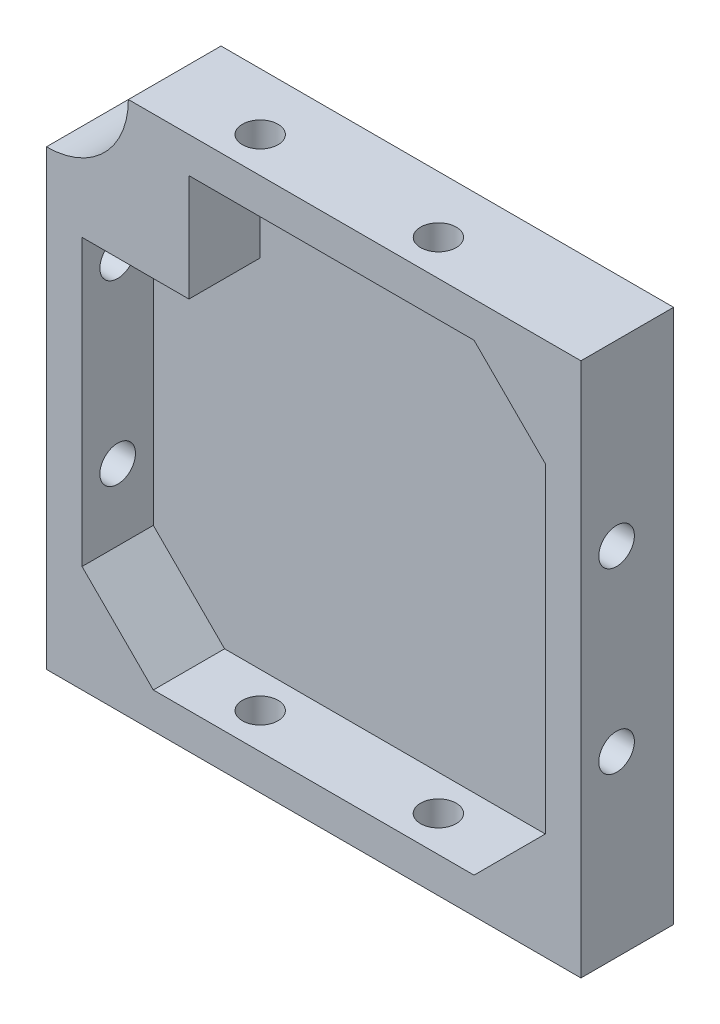
from build123d import *

# Parameters (mm, degrees)
BOSS_EXTRU_1_DEPTH        = 13
COQUE1_T                  = -5
COQUE1_THICKNESS_2_FACE_W = 65
COQUE1_THICKNESS_2_FACE_H = 65
COQUE1_THICKNESS_2_DEPTH  = 2
ENL_V_MAT_EXTRU_1_REACH   = 88.587
ESQUISSE2_R               = 2.5
ENL_V_MAT_EXTRU_2_REACH   = 95.396
ESQUISSE3_R               = 2.5
ESQUISSE4_W               = 15
ESQUISSE4_H               = 15
BOSS_EXTRU_2_DEPTH        = 10
ESQUISSE5_R               = 11.5
ENL_V_MAT_EXTRU_3_DEPTH   = 13


with BuildPart() as part:
    # Esquisse1 → Boss.-Extru.1 (new body)
    with BuildSketch(Plane.XY):
        Polygon((44.118436308, 33.728448276), (54.118436308, 33.728448276), (54.118436308, 23.728448276), (54.118436308, -41.271551724), (-20.881563692, -41.271551724), (-20.881563692, 33.728448276), align=None)
    extrude(amount=BOSS_EXTRU_1_DEPTH)

    # Coque1
    coque1_openings = [part.faces().sort_by_distance(p)[0] for p in [
        (16.618436308, -3.771551724, 13),
    ]]
    offset(amount=COQUE1_T, openings=coque1_openings, kind=Kind.INTERSECTION)

    # Coque1 thickness 2 face (on inner face of the shell) → Coque1 thickness 2 (cut)
    with BuildSketch(Plane(origin=(16.618436308, -3.771551724, 5), x_dir=(-1, 0, 0), z_dir=(0, 0, -1))):
        Rectangle(COQUE1_THICKNESS_2_FACE_W, COQUE1_THICKNESS_2_FACE_H)
    extrude(amount=COQUE1_THICKNESS_2_DEPTH, mode=Mode.SUBTRACT)

    # Enlèv. mat.-Extru.1: up to this face of the body (flat: up to its plane)
    enl_v_mat_extru_1_end = Plane(part.part.faces().sort_by_distance((54.118436308, -3.771551724, 6.5))[0])
    # Esquisse2 → Enlèv. mat.-Extru.1 (cut, up to the picked face)
    with BuildSketch(Plane.ZY.offset(20.881563692), mode=Mode.PRIVATE) as enl_v_mat_extru_1_sk1:
        with Locations(Location((8, -16.271551724, 0), (0, 0, 270))):
            Circle(ESQUISSE2_R)
    enl_v_mat_extru_1_tool1 = split(extrude(enl_v_mat_extru_1_sk1.sketch, amount=-ENL_V_MAT_EXTRU_1_REACH, mode=Mode.PRIVATE), bisect_by=enl_v_mat_extru_1_end, keep=Keep.BOTH, mode=Mode.PRIVATE)
    # Esquisse2 → Enlèv. mat.-Extru.1 (cut, up to the picked face)
    with BuildSketch(Plane.ZY.offset(20.881563692), mode=Mode.PRIVATE) as enl_v_mat_extru_1_sk2:
        with Locations(Location((8, 8.728448276, 0), (0, 0, 270))):
            Circle(ESQUISSE2_R)
    enl_v_mat_extru_1_tool2 = split(extrude(enl_v_mat_extru_1_sk2.sketch, amount=-ENL_V_MAT_EXTRU_1_REACH, mode=Mode.PRIVATE), bisect_by=enl_v_mat_extru_1_end, keep=Keep.BOTH, mode=Mode.PRIVATE)
    add(enl_v_mat_extru_1_tool1.solids().sort_by(Axis((-20.881564, -16.271552, 8), (1, 0, 0)))[0], mode=Mode.SUBTRACT)
    add(enl_v_mat_extru_1_tool2.solids().sort_by(Axis((-20.881564, 8.728448, 8), (1, 0, 0)))[0], mode=Mode.SUBTRACT)

    # Enlèv. mat.-Extru.2: up to this face of the body (flat: up to its plane)
    enl_v_mat_extru_2_end = Plane(part.part.faces().sort_by_distance((16.618436308, 33.728448276, 6.5))[0])
    # Esquisse3 → Enlèv. mat.-Extru.2 (cut, up to the picked face)
    with BuildSketch(Plane.XZ.offset(41.271551724), mode=Mode.PRIVATE) as enl_v_mat_extru_2_sk1:
        with Locations(Location((4.118436308, 8, 0), (0, 0, 270))):
            Circle(ESQUISSE3_R)
    enl_v_mat_extru_2_tool1 = split(extrude(enl_v_mat_extru_2_sk1.sketch, amount=-ENL_V_MAT_EXTRU_2_REACH, mode=Mode.PRIVATE), bisect_by=enl_v_mat_extru_2_end, keep=Keep.BOTH, mode=Mode.PRIVATE)
    # Esquisse3 → Enlèv. mat.-Extru.2 (cut, up to the picked face)
    with BuildSketch(Plane.XZ.offset(41.271551724), mode=Mode.PRIVATE) as enl_v_mat_extru_2_sk2:
        with Locations(Location((29.118436308, 8, 0), (0, 0, 270))):
            Circle(ESQUISSE3_R)
    enl_v_mat_extru_2_tool2 = split(extrude(enl_v_mat_extru_2_sk2.sketch, amount=-ENL_V_MAT_EXTRU_2_REACH, mode=Mode.PRIVATE), bisect_by=enl_v_mat_extru_2_end, keep=Keep.BOTH, mode=Mode.PRIVATE)
    add(enl_v_mat_extru_2_tool1.solids().sort_by(Axis((4.118436, -41.271552, 8), (0, 1, 0)))[0], mode=Mode.SUBTRACT)
    add(enl_v_mat_extru_2_tool2.solids().sort_by(Axis((29.118436, -41.271552, 8), (0, 1, 0)))[0], mode=Mode.SUBTRACT)

    # Esquisse4 → Boss.-Extru.2 (add)
    with BuildSketch(Plane.XY.offset(3)):
        Polygon((-15.881563692, -26.271551724), (-5.881563692, -36.271551724), (-15.881563692, -36.271551724), align=None)
        Polygon((49.118436308, 28.728448276), (49.118436308, 18.728448276), (39.118436308, 28.728448276), align=None)
        Polygon((49.118436308, -36.271551724), (49.118436308, -26.271551724), (39.118436308, -36.271551724), align=None)
        with Locations((-8.381563692, 21.228448276)):
            Rectangle(ESQUISSE4_W, ESQUISSE4_H)
    extrude(amount=BOSS_EXTRU_2_DEPTH)

    # Esquisse5 → Enlèv. mat.-Extru.3 (cut)
    with BuildSketch(Plane.XY.offset(13)):
        with Locations((-20.881563692, 33.728448276)):
            Circle(ESQUISSE5_R)
    extrude(amount=-ENL_V_MAT_EXTRU_3_DEPTH, mode=Mode.SUBTRACT)


solid = part.part
